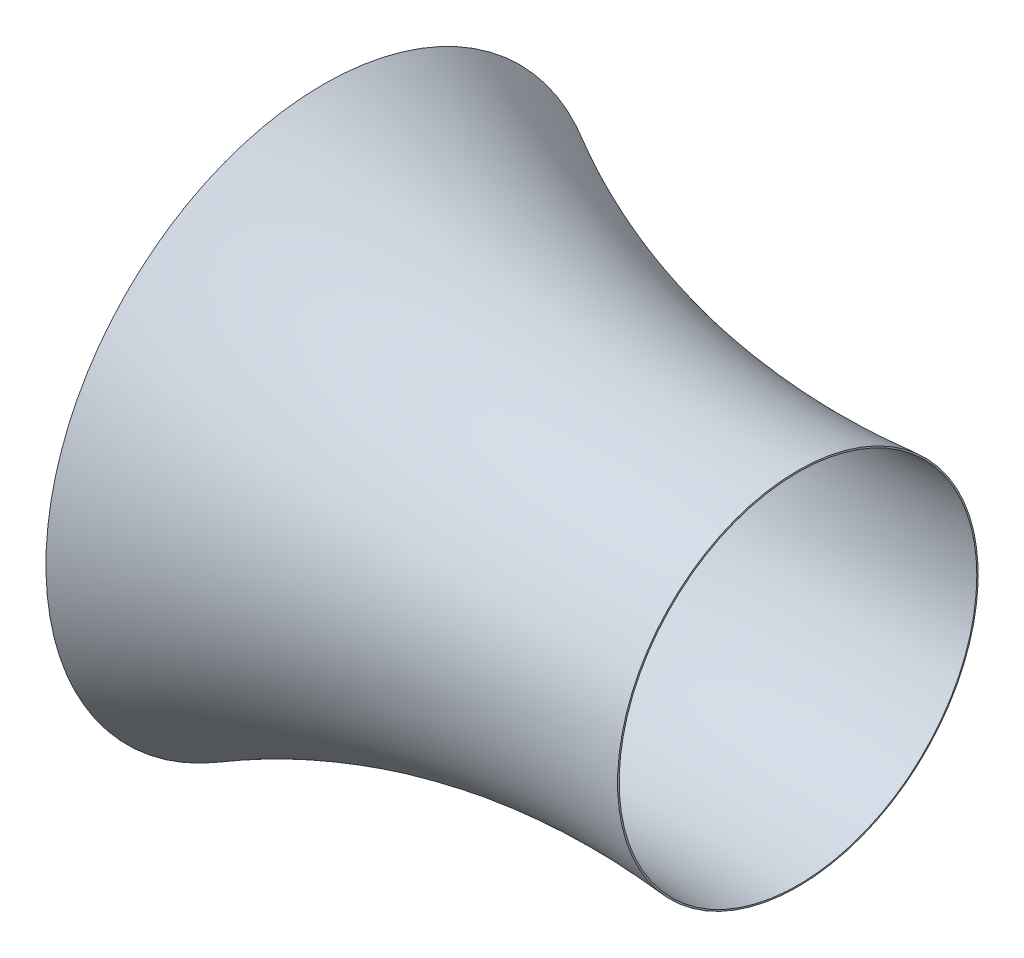
from build123d import *

# Parameters (mm, degrees)
THICKEN1_T1 = 5


with BuildPart() as body_1:
    # Surface-Revolve1: a surface, the sketch's curves turned about an axis
    with BuildLine(Plane.XY, mode=Mode.PRIVATE) as surface_revolve1_1_path:
        Line((58.164522356, 830), (33.164522356, 830))
        Line((33.164522356, 830), (25, 800))
        Line((25, 800), (0, 800))
        add(Edge.make_bspline(
            [(0, 800), (-40.64487716, 858.757553751), (0, 924.826053007)],
            knots=[0, 0, 0, 1, 1, 1], degree=2))
        add(Edge.make_bspline(
            [(0, 924.826053007), (729.903432622, 522.098602783), (1590, 600)],
            knots=[0, 0, 0, 1, 1, 1], degree=2))
    surface_revolve1_1 = Shell.revolve(surface_revolve1_1_path.wire(), 360, Axis((0, 0, 0), (1, 0, 0)))
    add(Solid.thicken(surface_revolve1_1, THICKEN1_T1))


solid = body_1.part
